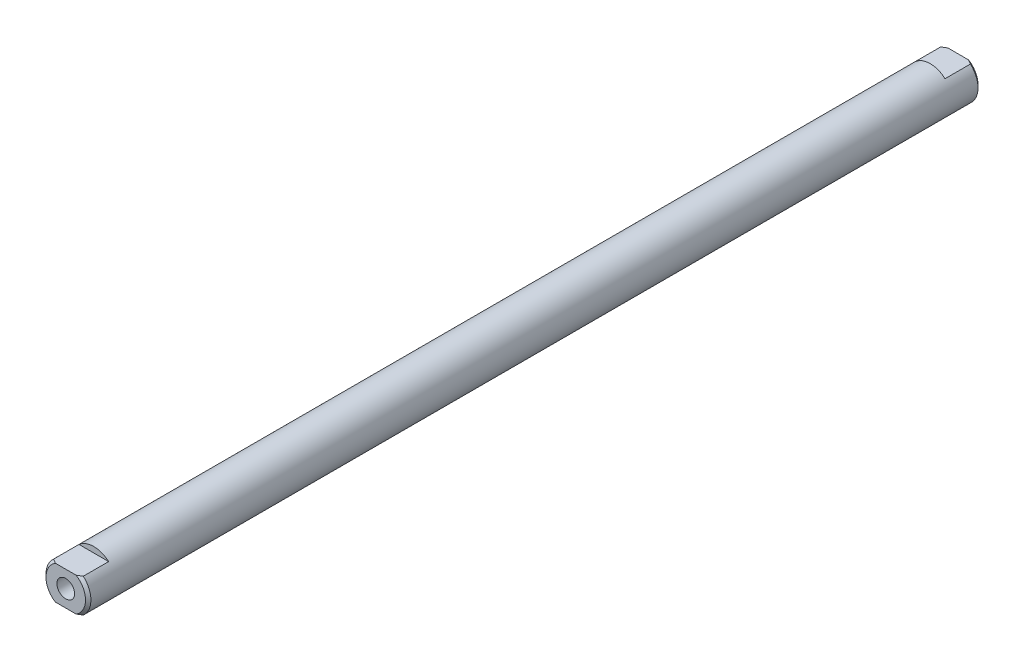
from build123d import *

# Parameters (mm, degrees)
SKETCH1_R           = 3.175
BOSS_EXTRUDE1_DEPTH = 63.119
CHAMFER1_SIZE       = 0.381
CUT_EXTRUDE1_DEPTH  = 3.96875


with BuildPart() as part:
    # Sketch1 → Boss-Extrude1 (new body, symmetric)
    with BuildSketch(Plane.XY):
        Circle(SKETCH1_R)
    extrude(amount=BOSS_EXTRUDE1_DEPTH, both=True)

    # Sketch4 → M3x0.5 Tapped Hole1 (revolve, cut)
    with BuildSketch(Plane(origin=(0, 0, 63.119), x_dir=(0, -1, 0), z_dir=(1, 0, 0))):
        Polygon((0, 0), (0, 8.244075774), (1.25, 7.493), (1.25, 0), align=None)
    m3x0_5_tapped_hole1 = revolve(axis=Axis((0, 0, 69.469), (0, 0, -1)), mode=Mode.SUBTRACT)

    # Chamfer1
    chamfer1_edges = [part.edges().sort_by_distance(p)[0] for p in [
        (-3.175, 0, -63.119),
        (-3.175, 0, 63.119),
    ]]
    chamfer(chamfer1_edges, length=CHAMFER1_SIZE)

    # Mirror1: M3x0.5 Tapped Hole1 across plane
    add(m3x0_5_tapped_hole1.mirror(Plane.XY), mode=Mode.SUBTRACT)

    # Sketch5 → Cut-Extrude1 (cut)
    with BuildSketch(Plane.XY.offset(63.119)):
        with BuildLine():
            Line((-2.100065103, 2.38125), (2.100065103, 2.38125))
            ThreePointArc((2.100065103, 2.38125), (0, 3.175), (-2.100065103, 2.38125))
        make_face()
        with BuildLine():
            Line((-2.100065103, -2.38125), (2.100065103, -2.38125))
            ThreePointArc((2.100065103, -2.38125), (0, -3.175), (-2.100065103, -2.38125))
        make_face()
    cut_extrude1 = extrude(amount=-CUT_EXTRUDE1_DEPTH, mode=Mode.SUBTRACT)

    # Mirror2: Cut-Extrude1 across plane
    add(cut_extrude1.mirror(Plane.XY), mode=Mode.SUBTRACT)


solid = part.part
